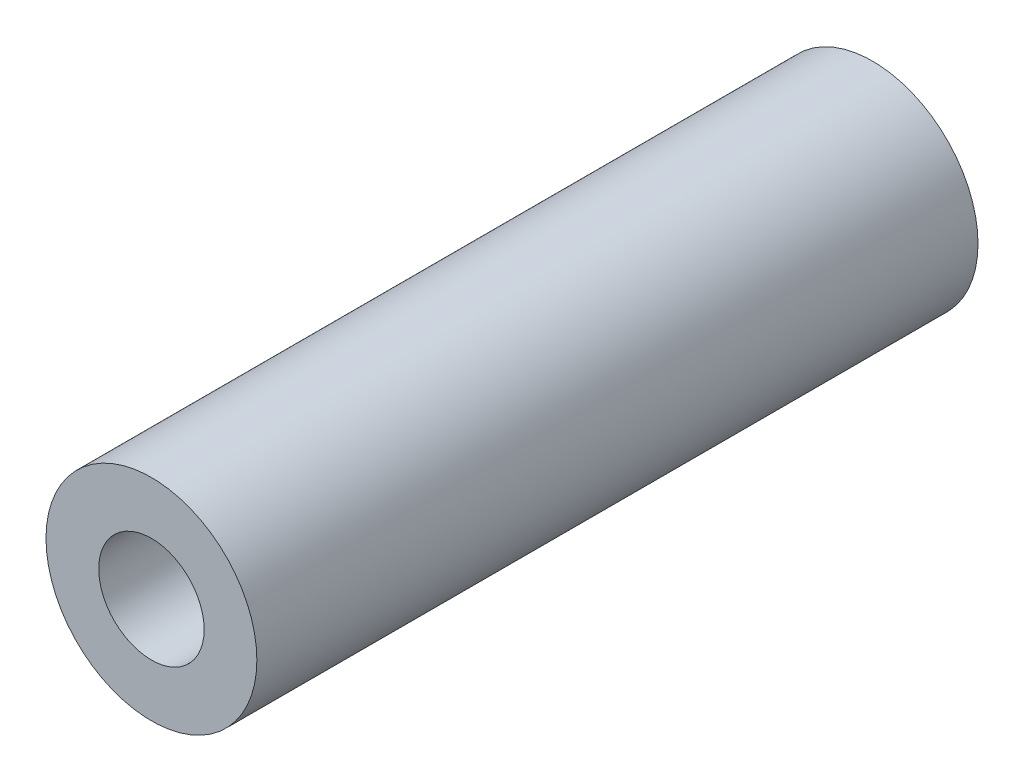
from build123d import *

# Parameters (mm, degrees)
SKETCH2_R           = 6.35
SKETCH2_R_2         = 3.175
BOSS_EXTRUDE1_DEPTH = 43.434


with BuildPart() as part:
    # Sketch2 → Boss-Extrude1 (new body)
    with BuildSketch(Plane.XY):
        Circle(SKETCH2_R)
        Circle(SKETCH2_R_2, mode=Mode.SUBTRACT)
    extrude(amount=BOSS_EXTRUDE1_DEPTH)


solid = part.part
